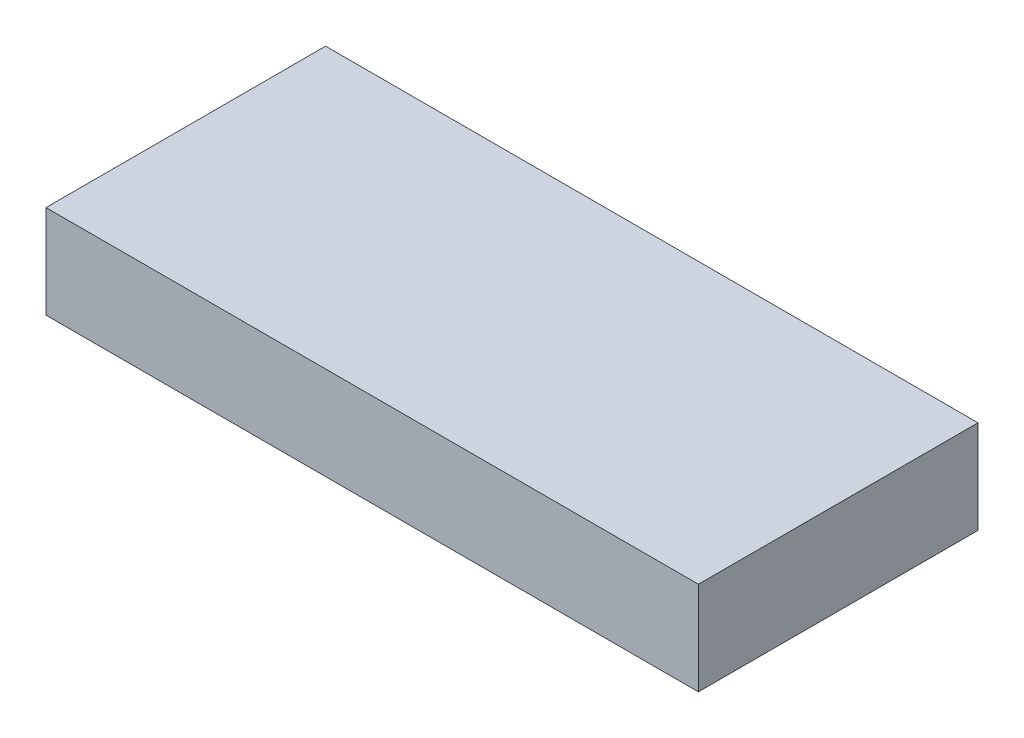
from build123d import *

# Parameters (mm, degrees)
SKETCH2_W           = 35
SKETCH2_H           = 15
BOSS_EXTRUDE1_DEPTH = 5


with BuildPart() as part:
    # Sketch2 → Boss-Extrude1 (new body)
    with BuildSketch(Plane(origin=(0, 0, 0), x_dir=(1, 0, 0), z_dir=(0, 1, 0))):
        Rectangle(SKETCH2_W, SKETCH2_H)
    extrude(amount=BOSS_EXTRUDE1_DEPTH)


solid = part.part
